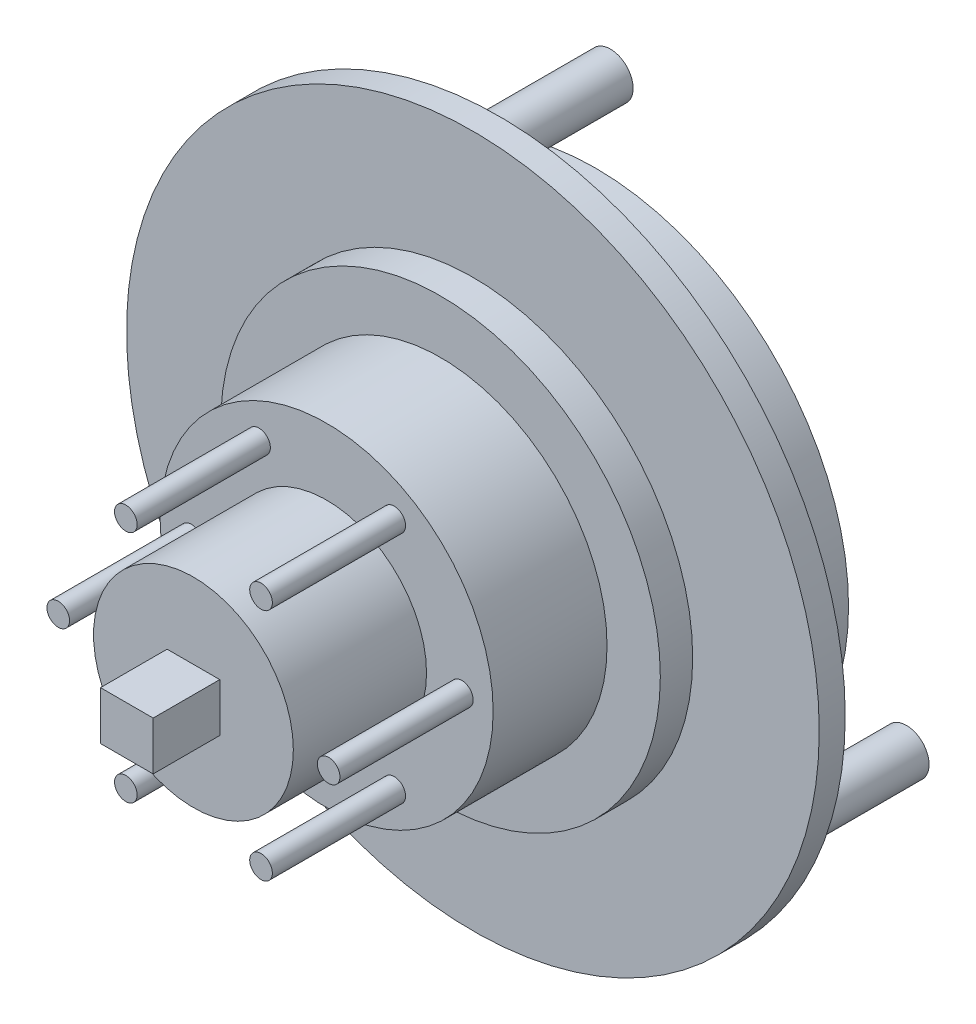
from build123d import *

# Parameters (mm, degrees)
SKETCH1_R           = 26
BOSS_EXTRUDE1_DEPTH = 1.95
SKETCH2_R           = 19
BOSS_EXTRUDE2_DEPTH = 7.25
SKETCH3_R           = 16.5
BOSS_EXTRUDE3_DEPTH = 2.43
SKETCH4_R           = 12.5
BOSS_EXTRUDE4_DEPTH = 8.55
SKETCH5_R           = 7.5
BOSS_EXTRUDE5_DEPTH = 10
SKETCH6_R           = 1.7
BOSS_EXTRUDE6_DEPTH = 10
SKETCH7_R           = 0.85
BOSS_EXTRUDE7_DEPTH = 10
SKETCH8_W           = 3.953217044
SKETCH8_H           = 3.634424256
BOSS_EXTRUDE8_DEPTH = 5


with BuildPart() as part:
    # Sketch1 → Boss-Extrude1 (new body)
    with BuildSketch(Plane.XY):
        Circle(SKETCH1_R)
    extrude(amount=BOSS_EXTRUDE1_DEPTH)

    # Sketch2 → Boss-Extrude2 (add)
    with BuildSketch(Plane(origin=(0, 0, 0), x_dir=(-1, 0, 0), z_dir=(0, 0, -1))):
        Circle(SKETCH2_R)
    extrude(amount=BOSS_EXTRUDE2_DEPTH)

    # Sketch3 → Boss-Extrude3 (add)
    with BuildSketch(Plane.XY.offset(1.95)):
        Circle(SKETCH3_R)
    extrude(amount=BOSS_EXTRUDE3_DEPTH)

    # Sketch4 → Boss-Extrude4 (add)
    with BuildSketch(Plane.XY.offset(4.38)):
        Circle(SKETCH4_R)
    extrude(amount=BOSS_EXTRUDE4_DEPTH)

    # Sketch5 → Boss-Extrude5 (add)
    with BuildSketch(Plane.XY.offset(12.93)):
        Circle(SKETCH5_R)
    extrude(amount=BOSS_EXTRUDE5_DEPTH)

    # Sketch6 → Boss-Extrude6 (add)
    with BuildSketch(Plane(origin=(0, 0, 0), x_dir=(-1, 0, 0), z_dir=(0, 0, -1))):
        with Locations((18.970004687, -12.827662382)):
            Circle(SKETCH6_R)
        with Locations((-20.594083837, -10.014674777)):
            Circle(SKETCH6_R)
        with Locations((1.624079151, 22.84233716)):
            Circle(SKETCH6_R)
    extrude(amount=BOSS_EXTRUDE6_DEPTH)

    # Sketch7 → Boss-Extrude7 (add)
    with BuildSketch(Plane.XY.offset(12.93)):
        with Locations((-10.15, 0)):
            Circle(SKETCH7_R)
        with Locations((-5.075, 8.790157848)):
            Circle(SKETCH7_R)
        with Locations((5.075, 8.790157848)):
            Circle(SKETCH7_R)
        with Locations((10.15, 0)):
            Circle(SKETCH7_R)
        with Locations((5.075, -8.790157848)):
            Circle(SKETCH7_R)
        with Locations((-5.075, -8.790157848)):
            Circle(SKETCH7_R)
    extrude(amount=BOSS_EXTRUDE7_DEPTH)

    # Sketch8 → Boss-Extrude8 (add)
    with BuildSketch(Plane.XY.offset(22.93)):
        Rectangle(SKETCH8_W, SKETCH8_H)
    extrude(amount=BOSS_EXTRUDE8_DEPTH)


solid = part.part
